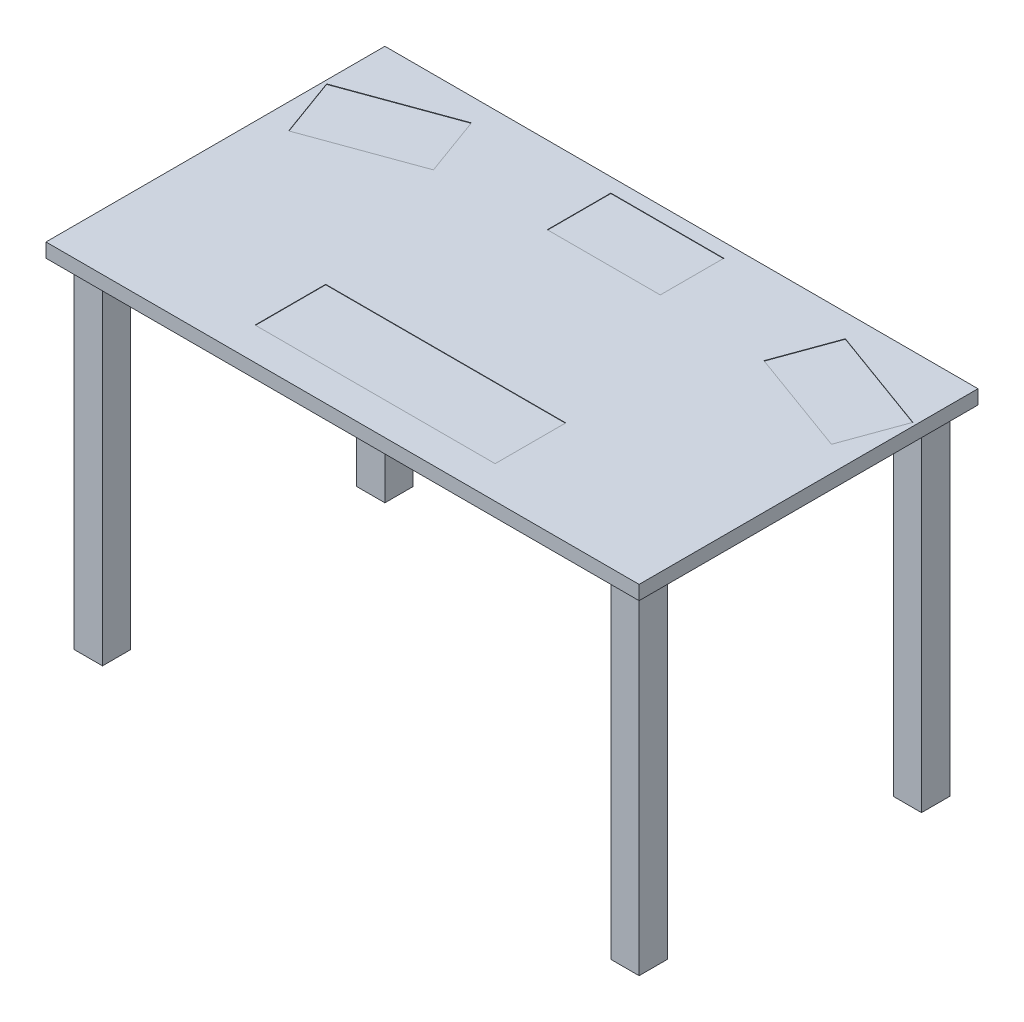
from build123d import *

# Parameters (mm, degrees)
SKETCH1_W             = 50.8
SKETCH1_H             = 50.8
BOSS_EXTRUDE1_DEPTH   = 609.6
BOSS_EXTRUDE1_2_DEPTH = 609.6
BOSS_EXTRUDE1_3_DEPTH = 609.6
BOSS_EXTRUDE1_4_DEPTH = 609.6
SKETCH2_W             = 1066.8
SKETCH2_H             = 609.6
BOSS_EXTRUDE2_DEPTH   = 25.4
SKETCH3_W             = 203.2
SKETCH3_H             = 114.3
SKETCH3_W_2           = 431.8
SKETCH3_H_2           = 127
CUT_EXTRUDE1_DEPTH    = 0.79375


with BuildPart() as part:
    # Sketch1 → Boss-Extrude1 (new body)
    with BuildSketch(Plane(origin=(0, 0, 0), x_dir=(1, 0, 0), z_dir=(0, 1, 0))):
        with Locations((25.4, 25.4)):
            Rectangle(SKETCH1_W, SKETCH1_H)
    extrude(amount=BOSS_EXTRUDE1_DEPTH)



with BuildPart() as body_2:
    # Sketch1 → Boss-Extrude1 2 (new body)
    with BuildSketch(Plane(origin=(0, 0, 0), x_dir=(1, 0, 0), z_dir=(0, 1, 0))):
        with Locations((25.4, 533.4)):
            Rectangle(SKETCH1_W, SKETCH1_H)
    extrude(amount=BOSS_EXTRUDE1_2_DEPTH)


with BuildPart() as body_3:
    # Sketch1 → Boss-Extrude1 3 (new body)
    with BuildSketch(Plane(origin=(0, 0, 0), x_dir=(1, 0, 0), z_dir=(0, 1, 0))):
        with Locations((990.6, 533.4)):
            Rectangle(SKETCH1_W, SKETCH1_H)
    extrude(amount=BOSS_EXTRUDE1_3_DEPTH)


with BuildPart() as body_4:
    # Sketch1 → Boss-Extrude1 4 (new body)
    with BuildSketch(Plane(origin=(0, 0, 0), x_dir=(1, 0, 0), z_dir=(0, 1, 0))):
        with Locations((990.6, 25.4)):
            Rectangle(SKETCH1_W, SKETCH1_H)
    extrude(amount=BOSS_EXTRUDE1_4_DEPTH)


with BuildPart() as part_1:
    add(part.part)

    add(body_2.part)  # Boss-Extrude2 merges body 2

    add(body_3.part)  # Boss-Extrude2 merges body 3

    add(body_4.part)  # Boss-Extrude2 merges body 4
    # Sketch2 → Boss-Extrude2 (add)
    with BuildSketch(Plane(origin=(0, 609.6, 0), x_dir=(1, 0, 0), z_dir=(0, 1, 0))):
        with Locations((508, 279.4)):
            Rectangle(SKETCH2_W, SKETCH2_H)
    extrude(amount=BOSS_EXTRUDE2_DEPTH)

    # Sketch3 → Cut-Extrude1 (cut)
    with BuildSketch(Plane(origin=(0, 635, 0), x_dir=(1, 0, 0), z_dir=(0, 1, 0))):
        Polygon((210.765672654, 435.342380006), (19.82013211, 365.843886882), (-19.272770272, 473.250753438), (171.672770272, 542.749246562), align=None)
        with Locations((508, 501.65)):
            Rectangle(SKETCH3_W, SKETCH3_H)
        Polygon((844.327229728, 542.749246562), (1035.272770272, 473.250753438), (996.17986789, 365.843886882), (805.234327346, 435.342380006), align=None)
        with Locations((508, 96.68413443)):
            Rectangle(SKETCH3_W_2, SKETCH3_H_2)
    extrude(amount=-CUT_EXTRUDE1_DEPTH, mode=Mode.SUBTRACT)


solid = part_1.part
